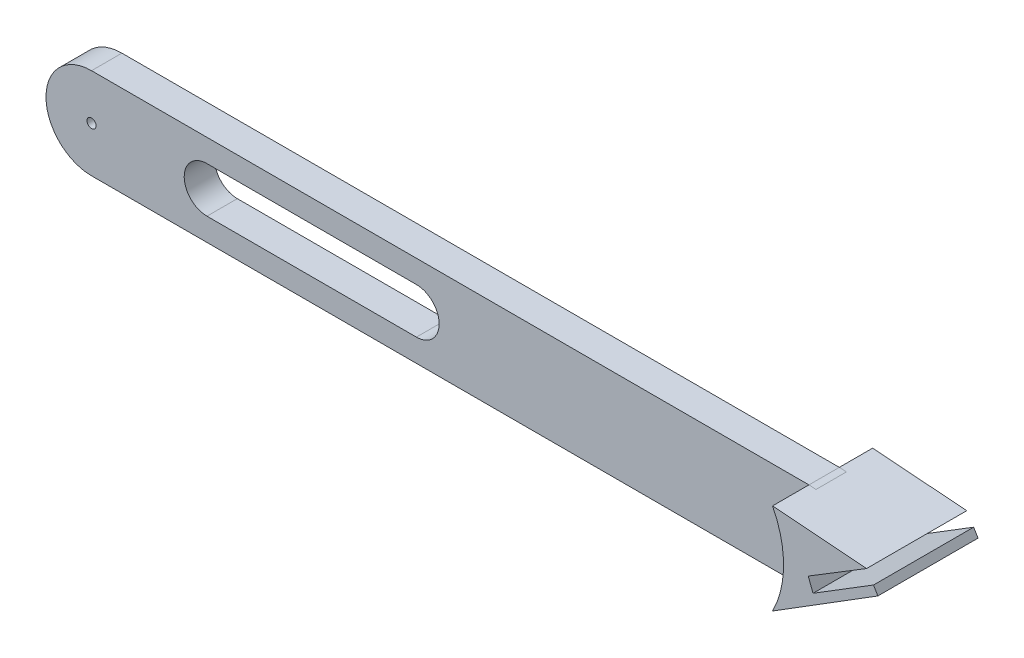
from build123d import *

# Parameters (mm, degrees)
EXTRUDE_1_DEPTH      = 1.4
EXTRUDE_1_DEPTH_BACK = 1.935048816
MM_1_D               = 1
MM_1_DEPTH           = 3.69956969
MM_1_TIP             = 0.30043031
MM_2_D               = 1
MM_2_DEPTH           = 3.69956969
MM_2_TIP             = 0.30043031
EXTRUDE_4_DEPTH      = 4
EXTRUDE_4_DEPTH_BACK = 7
CUT_EXTRUDE_4_DEPTH  = 4


with BuildPart() as part:
    # 草图1 → 凸台-拉伸1 (new body, two sides)
    with BuildSketch(Plane.XY) as extrude_1_sk:
        with BuildLine():
            Line((-14, 10.976009084), (64.784112274, 10.976009084))
            ThreePointArc((64.784112274, 10.976009084), (69.784112274, 5.976009084), (64.784112274, 0.976009084))
            Line((64.784112274, 0.976009084), (-14, 0.976009084))
            ThreePointArc((-14, 0.976009084), (-19, 5.976009084), (-14, 10.976009084))
        make_face()
        with BuildLine():
            Line((21.676320512, 3.476009084), (-1.323679488, 3.476009084))
            ThreePointArc((-1.323679488, 3.476009084), (-3.823679488, 5.976009084), (-1.323679488, 8.476009084))
            Line((-1.323679488, 8.476009084), (21.676320512, 8.476009084))
            ThreePointArc((21.676320512, 8.476009084), (24.176320512, 5.976009084), (21.676320512, 3.476009084))
        make_face(mode=Mode.SUBTRACT)
    extrude(amount=EXTRUDE_1_DEPTH)
    extrude(extrude_1_sk.sketch, amount=-EXTRUDE_1_DEPTH_BACK)

    # 大小mm 暗销孔1
    with Locations(Plane(origin=(0, 0, -1.935048816), x_dir=(-1, 0, 0), z_dir=(0, 0, -1))):
        with Locations((14, 5.976009084)):
            Hole(MM_1_D / 2, depth=MM_1_DEPTH)
            with Locations((0, 0, -(MM_1_DEPTH + MM_1_TIP / 2))):  # 118° drill point
                Cone(0, MM_1_D / 2, MM_1_TIP, mode=Mode.SUBTRACT)

    # 大小mm 暗销孔2
    with Locations(Plane(origin=(0, 0, -1.935048816), x_dir=(-1, 0, 0), z_dir=(0, 0, -1))):
        with Locations((-64.784112274, 5.976009084)):
            Hole(MM_2_D / 2, depth=MM_2_DEPTH)
            with Locations((0, 0, -(MM_2_DEPTH + MM_2_TIP / 2))):  # 118° drill point
                Cone(0, MM_2_D / 2, MM_2_TIP, mode=Mode.SUBTRACT)

    # 草图11 → 凸台-拉伸4 (add, two sides)
    with BuildSketch(Plane.XY.offset(1.4)) as extrude_4_sk:
        with BuildLine():
            Line((64.784112274, 10.976009084), (75.11027427, 10.181945777))
            Line((75.11027427, 10.181945777), (68.706480161, 6.265649051))
            Line((68.706480161, 6.265649051), (69.231074418, 4.88985116))
            Line((69.231074418, 4.88985116), (75.876804715, 9.001268784))
            Line((75.876804715, 9.001268784), (76.348764637, 8.189866665))
            Line((76.348764637, 8.189866665), (64.784112274, 0.976009084))
            ThreePointArc((64.784112274, 0.976009084), (65.998123298, 5.976009084), (64.784112274, 10.976009084))
        make_face()
    extrude(amount=EXTRUDE_4_DEPTH)
    extrude(extrude_4_sk.sketch, amount=-EXTRUDE_4_DEPTH_BACK)

    # 草图12 → 切除-拉伸4 (cut)
    with BuildSketch(Plane.XY.offset(1.4)):
        Polygon((69.702654004, 6.874867944), (68.706480161, 6.265649051), (69.231074418, 4.88985116), (69.722566431, 5.193915399), (71.19681176, 6.105965386), align=None)
        Polygon((64.784112274, 0.976009084), (69.274656978, 3.777143865), (71.000307029, 3.200660754), (64.195477274, -1.252602435), align=None)
    extrude(amount=-CUT_EXTRUDE_4_DEPTH, mode=Mode.SUBTRACT)


solid = part.part
